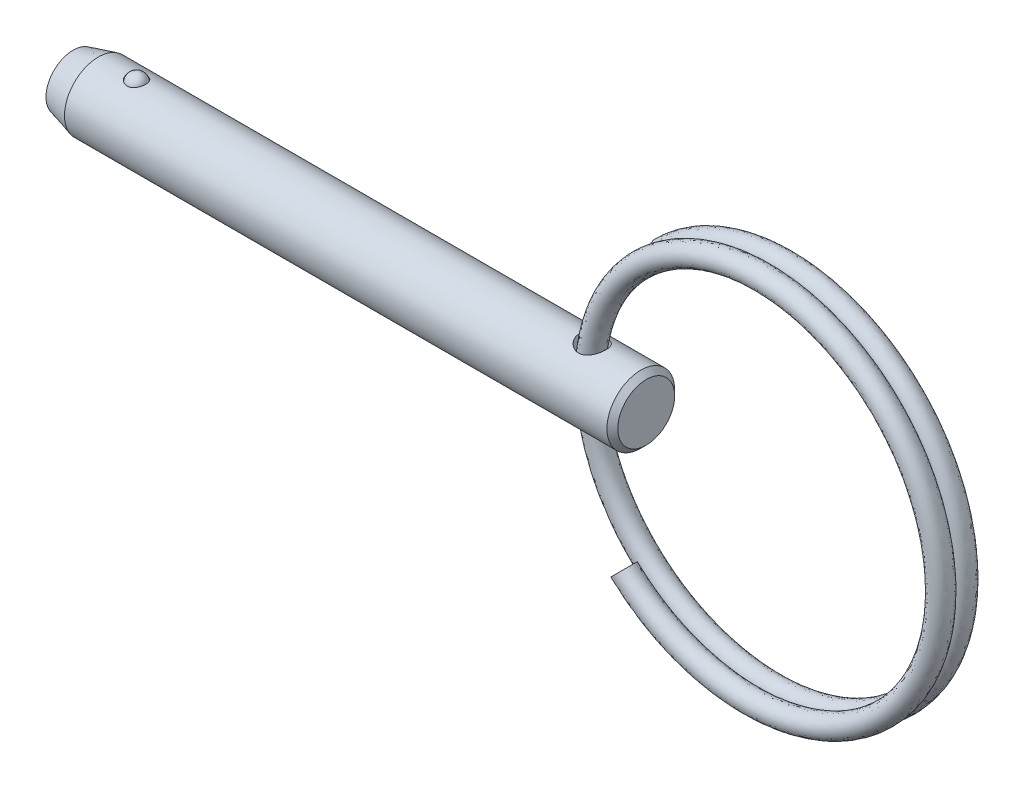
from build123d import *

# Parameters (mm, degrees)
SKETCH4_W          = 0.9525
SKETCH4_H          = 4.7625
SWEEP1_PITCH       = 1.5494
SWEEP1_HEIGHT      = 1.355725
SWEEP1_RADIUS      = 13.462
SKETCH6_R          = 0.762
SWEEP2_PITCH       = 1.5494
SWEEP2_HEIGHT      = 1.355725
SWEEP2_RADIUS      = 13.462
SWEEP2_START_ANGLE = -180
SKETCH6_2_R        = 0.762


with BuildPart() as part:
    # Sketch1 → Revolve1 (revolve)
    with BuildSketch(Plane.XY):
        Polygon((20.1549, 2.00025), (19.7739, 2.38125), (-18.377510803, 2.38125), (-20.1549, 1.905), (-20.1549, 0), (20.1549, 0), align=None)
    revolve(axis=Axis((20.1549, 0, 0), (1, 0, 0)))

    # Sketch2 → Cut-Revolve1 (revolve, cut)
    with BuildSketch(Plane.XY):
        with BuildLine():
            Line((-15.004844331, 2.143125), (-16.370094331, 2.143125))
            ThreePointArc((-16.370094331, 2.143125), (-15.687469331, 2.82575), (-15.004844331, 2.143125))
        make_face()
    revolve(axis=Axis((-15.004844331, 2.143125, 0), (1, 0, 0)), mode=Mode.SUBTRACT)

    # Sketch4 → Cut-Revolve2 (revolve, cut)
    with BuildSketch(Plane.XY):
        with Locations((16.83385, 0)):
            Rectangle(SKETCH4_W, SKETCH4_H)
    revolve(axis=Axis((16.3576, -2.38125, 0), (0, 1, 0)), mode=Mode.SUBTRACT)


with BuildPart() as body_2:
    # Sketch3 → Revolve2 (revolve)
    with BuildSketch(Plane.XY):
        with BuildLine():
            Line((-15.030244331, 2.143125), (-16.344694331, 2.143125))
            ThreePointArc((-16.344694331, 2.143125), (-15.687469331, 2.80035), (-15.030244331, 2.143125))
        make_face()
    revolve(axis=Axis((-15.030244331, 2.143125, 0), (1, 0, 0)))


with BuildPart() as body_3:
    # Sweep1: sweep along a helix
    with BuildLine() as sweep1_path:
        Helix(SWEEP1_PITCH, SWEEP1_HEIGHT, SWEEP1_RADIUS, center=(28.937648906, 0, 0), direction=(0, 0, -1), lefthand=True)
    # Sketch6 → Sweep1 (sweep)
    with BuildSketch(Plane(origin=(114.003847968, 0, 0), x_dir=(0, 0, -1), z_dir=(0, 1, 0))):
        with Locations((0, 97.766199061)):
            Circle(SKETCH6_R)
    sweep(path=sweep1_path.line, is_frenet=True)

    # Sweep2: sweep along a helix
    with BuildLine() as sweep2_path:
        add(Helix(SWEEP2_PITCH, SWEEP2_HEIGHT, SWEEP2_RADIUS, center=(28.937648906, 0, 0), direction=(0, 0, 1), lefthand=True, mode=Mode.PRIVATE).rotate(Axis((28.937648906, 0, 0), (0, 0, 1)), SWEEP2_START_ANGLE))
    # Sketch6_2 → Sweep2 (sweep)
    with BuildSketch(Plane(origin=(114.003847968, 0, 0), x_dir=(0, 0, -1), z_dir=(0, 1, 0))):
        with Locations((0, 97.766199061)):
            Circle(SKETCH6_2_R)
    sweep(path=sweep2_path.line, is_frenet=True)


solid = Compound([part.part, body_2.part, body_3.part])
